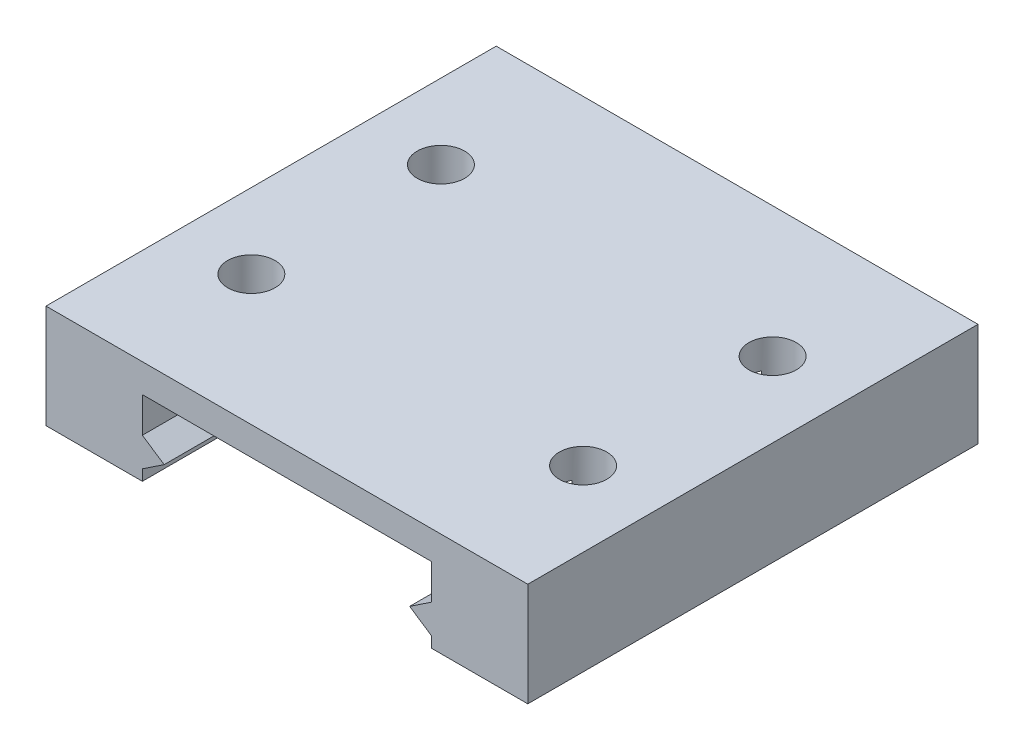
from build123d import *

# Parameters (mm, degrees)
BOSS_EXTRUDE1_DEPTH = 28.5
SKETCH2_R           = 1.5
CUT_EXTRUDE1_DEPTH  = 3


with BuildPart() as part:
    # Sketch1 → Boss-Extrude1 (new body)
    with BuildSketch(Plane.XY):
        Polygon((-9.15, -1.105576246), (-9.15, -0.419722436), (-7.770416346, 0.5), (-9.15, 1.419722436), (-9.15, 3.65), (9.15, 3.65), (9.15, 1.419722436), (7.770416346, 0.5), (9.15, -0.419722436), (9.15, -1.105576246), (15.25, -1.105576246), (15.25, 5.45289456), (-15.25, 5.45289456), (-15.25, -1.105576246), align=None)
    extrude(amount=-BOSS_EXTRUDE1_DEPTH)

    # Sketch2 → Cut-Extrude1 (cut)
    with BuildSketch(Plane(origin=(0, 5.45289456, 0), x_dir=(1, 0, 0), z_dir=(0, 1, 0))):
        with Locations((-10.5, 8.25)):
            Circle(SKETCH2_R)
        with Locations((-10.5, 20.25)):
            Circle(SKETCH2_R)
        with Locations((10.5, 20.25)):
            Circle(SKETCH2_R)
        with Locations((10.5, 8.25)):
            Circle(SKETCH2_R)
    extrude(amount=-CUT_EXTRUDE1_DEPTH, mode=Mode.SUBTRACT)


solid = part.part
